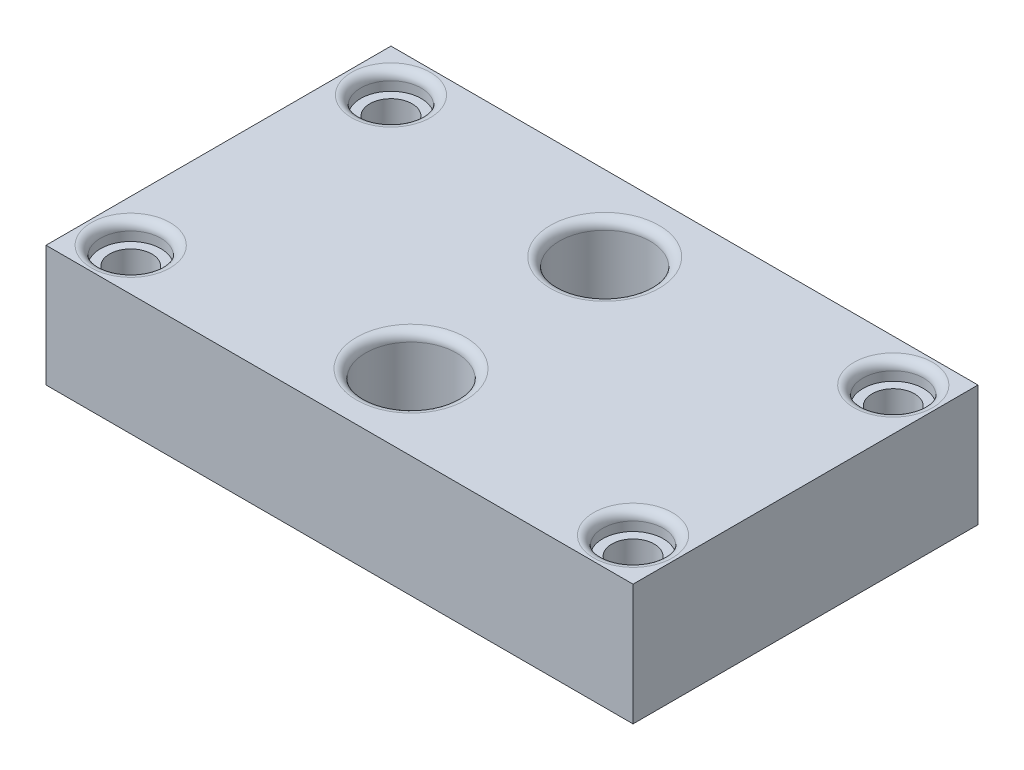
from build123d import *

# Parameters (mm, degrees)
SKETCH1_W           = 97
SKETCH1_H           = 57
BOSS_EXTRUDE1_DEPTH = 20
SKETCH2_R           = 3.5
CUT_EXTRUDE1_DEPTH  = 10
SKETCH3_R           = 5
CUT_EXTRUDE2_DEPTH  = 3
SKETCH4_R           = 7.5
CUT_EXTRUDE3_DEPTH  = 21
FILLET1_R           = 1.5


with BuildPart() as part:
    # Sketch1 → Boss-Extrude1 (new body)
    with BuildSketch(Plane(origin=(0, 515.957940224, 0), x_dir=(1, 0, 0), z_dir=(0, 1, 0))):
        with Locations((-575.759361975, 0)):
            Rectangle(SKETCH1_W, SKETCH1_H)
    extrude(amount=BOSS_EXTRUDE1_DEPTH)

    # Sketch2 → Cut-Extrude1 (cut)
    with BuildSketch(Plane(origin=(0, 535.957940224, 0), x_dir=(1, 0, 0), z_dir=(0, 1, 0))):
        with Locations((-534.259361975, 21.5)):
            Circle(SKETCH2_R)
        with Locations((-617.259361975, 21.5)):
            Circle(SKETCH2_R)
        with Locations((-534.259361975, -21.5)):
            Circle(SKETCH2_R)
        with Locations((-617.259361975, -21.5)):
            Circle(SKETCH2_R)
    extrude(amount=-CUT_EXTRUDE1_DEPTH, mode=Mode.SUBTRACT)

    # Sketch3 → Cut-Extrude2 (cut)
    with BuildSketch(Plane(origin=(0, 535.957940224, 0), x_dir=(1, 0, 0), z_dir=(0, 1, 0))):
        with Locations((-534.259361975, 21.5)):
            Circle(SKETCH3_R)
        with Locations((-617.259361975, 21.5)):
            Circle(SKETCH3_R)
        with Locations((-617.259361975, -21.5)):
            Circle(SKETCH3_R)
        with Locations((-534.259361975, -21.5)):
            Circle(SKETCH3_R)
    extrude(amount=-CUT_EXTRUDE2_DEPTH, mode=Mode.SUBTRACT)

    # Sketch4 → Cut-Extrude3 (cut, through all)
    with BuildSketch(Plane(origin=(0, 535.957940224, 0), x_dir=(1, 0, 0), z_dir=(0, 1, 0))):
        with Locations((-576.441550421, 16)):
            Circle(SKETCH4_R)
        with Locations((-576.441550421, -16)):
            Circle(SKETCH4_R)
    extrude(amount=-CUT_EXTRUDE3_DEPTH, mode=Mode.SUBTRACT)

    # Fillet1
    fillet1_edges = [part.edges().sort_by_distance(p)[0] for p in [
        (-539.259361975, 535.957940224, 21.5),
        (-622.259361975, 535.957940224, 21.5),
        (-622.259361975, 535.957940224, -21.5),
        (-539.259361975, 535.957940224, -21.5),
        (-583.941550421, 535.957940224, -16),
        (-583.941550421, 535.957940224, 16),
    ]]
    fillet(fillet1_edges, radius=FILLET1_R)


solid = part.part
